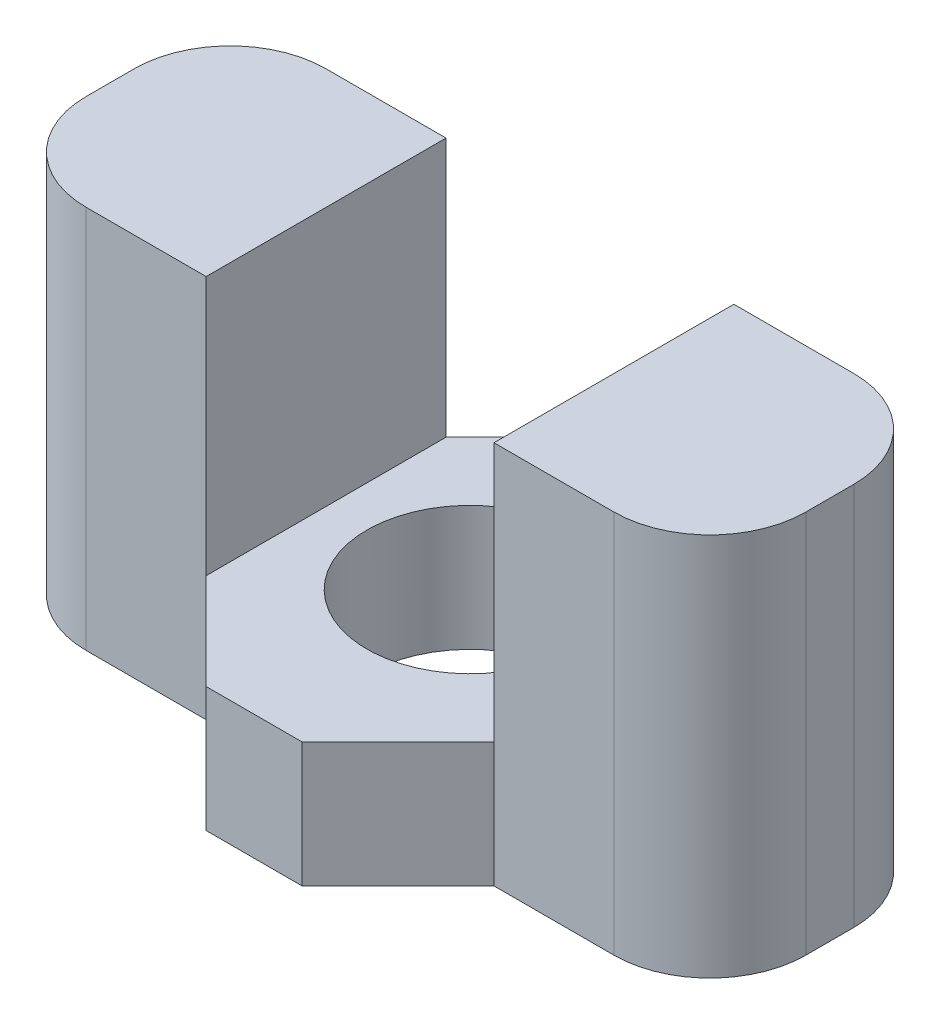
from build123d import *

# Parameters (mm, degrees)
SKETCH_1_W               = 15
SKETCH_1_H               = 5
SKETCH_1_R               = 2.15
SKETCH_1_R_2             = 2.075
EXTRUDE_1_DEPTH          = 8
SKETCH_1_3_R             = 2.075
CUT_EXTRUDE_1_DEPTH      = 2
SKETCH_2_W               = 3
SKETCH_2_H               = 5.4
CUT_EXTRUDE_2_DEPTH      = 3.5
CUT_EXTRUDE_2_DEPTH_BACK = 3.5
EXTRUDE_2_DEPTH          = 2.6
FILLET_1_R               = 2


with BuildPart() as part:
    # 草图1 → 凸台-拉伸1 (new body)
    with BuildSketch(Plane(origin=(0, 0, 0), x_dir=(1, 0, 0), z_dir=(0, 1, 0))):
        Rectangle(SKETCH_1_W, SKETCH_1_H)
        Circle(SKETCH_1_R, mode=Mode.SUBTRACT)
        with Locations((-5, 0)):
            Circle(SKETCH_1_R_2, mode=Mode.SUBTRACT)
        with Locations((5, 0)):
            Circle(SKETCH_1_R_2, mode=Mode.SUBTRACT)
        with Locations((-5, 0)):
            Circle(SKETCH_1_R_2)
        with Locations((5, 0)):
            Circle(SKETCH_1_R_2)
    extrude(amount=EXTRUDE_1_DEPTH)

    # 草图1<3> → 切除-拉伸1 (cut)
    with BuildSketch(Plane(origin=(0, 0, 0), x_dir=(1, 0, 0), z_dir=(0, 1, 0))):
        with Locations((-5, 0)):
            Circle(SKETCH_1_3_R)
        with Locations((5, 0)):
            Circle(SKETCH_1_3_R)
    extrude(amount=CUT_EXTRUDE_1_DEPTH, mode=Mode.SUBTRACT)

    # 草图2 → 切除-拉伸2 (cut, two sides)
    with BuildSketch(Plane.XY) as cut_extrude_2_sk:
        with Locations((-1.5, 5.3)):
            Rectangle(SKETCH_2_W, SKETCH_2_H)
        with Locations((1.5, 5.3)):
            Rectangle(SKETCH_2_W, SKETCH_2_H)
    extrude(amount=CUT_EXTRUDE_2_DEPTH, mode=Mode.SUBTRACT)
    extrude(cut_extrude_2_sk.sketch, amount=-CUT_EXTRUDE_2_DEPTH_BACK, mode=Mode.SUBTRACT)

    # 草图3 → 凸台-拉伸2 (add)
    with BuildSketch(Plane(origin=(0, 0, 0), x_dir=(1, 0, 0), z_dir=(0, 1, 0))):
        Polygon((-1, 4.5), (-3, 2.5), (0, 2.5), (0, 4.5), align=None)
        Polygon((0, 4.5), (0, 2.5), (3, 2.5), (1, 4.5), align=None)
        Polygon((3, -2.5), (0, -2.5), (0, -4.5), (1, -4.5), align=None)
        Polygon((0, -2.5), (-3, -2.5), (-1, -4.5), (0, -4.5), align=None)
    extrude(amount=EXTRUDE_2_DEPTH)

    # 圆角1
    fillet_1_edges = [part.edges().sort_by_distance(p)[0] for p in [
        (7.5, 4, 2.5),
        (-7.5, 4, 2.5),
        (-7.5, 4, -2.5),
        (7.5, 4, -2.5),
    ]]
    fillet(fillet_1_edges, radius=FILLET_1_R)


solid = part.part
